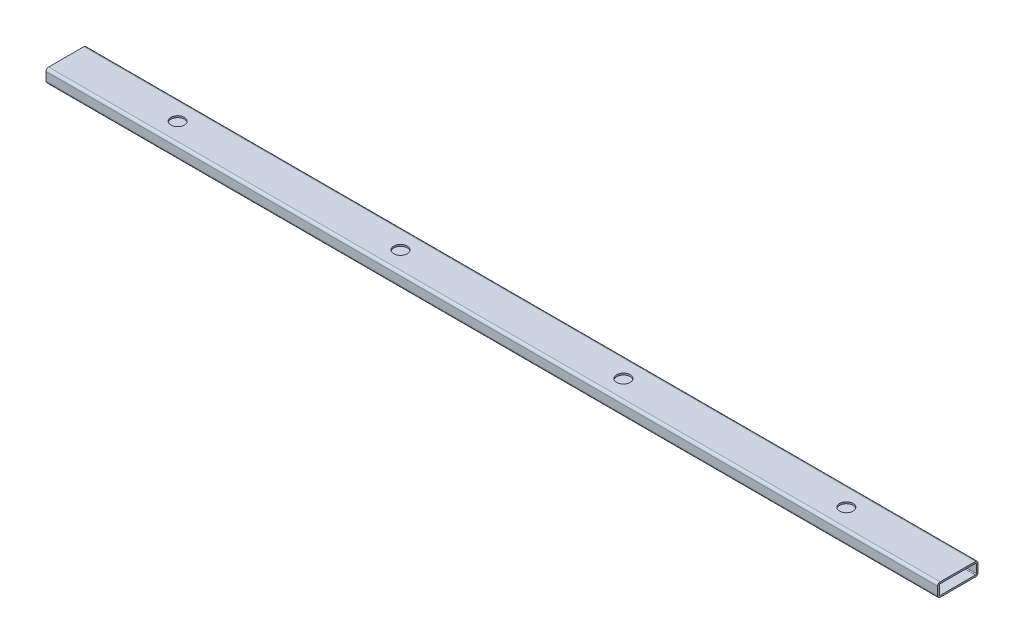
from build123d import *

# Parameters (mm, degrees)
BOSS_EXTRUDE1_DEPTH = 841.375
SKETCH2_R           = 12.7
CUT_EXTRUDE1_DEPTH  = 3.175
LPATTERN1_COUNT     = 4
LPATTERN1_PITCH     = 420.6875


with BuildPart() as part:
    # Sketch1 → Boss-Extrude1 (new body, symmetric)
    with BuildSketch(Plane(origin=(0, 0, 0), x_dir=(0, 0, -1), z_dir=(1, 0, 0))):
        with BuildLine():
            Line((33.3248, 25.4), (-33.3248, 25.4))
            ThreePointArc((-33.3248, 25.4), (-36.701376302, 24.001376302), (-38.1, 20.6248))
            Line((-38.1, 20.6248), (-38.1, 4.7752))
            ThreePointArc((-38.1, 4.7752), (-36.701376302, 1.398623698), (-33.3248, 0))
            Line((-33.3248, 0), (33.3248, 0))
            ThreePointArc((33.3248, 0), (36.701376302, 1.398623698), (38.1, 4.7752))
            Line((38.1, 4.7752), (38.1, 20.6248))
            ThreePointArc((38.1, 20.6248), (36.701376302, 24.001376302), (33.3248, 25.4))
        make_face()
        with BuildLine():
            Line((33.3248, 22.225), (-33.3248, 22.225))
            ThreePointArc((-33.3248, 22.225), (-34.456312271, 21.756312271), (-34.925, 20.6248))
            Line((-34.925, 20.6248), (-34.925, 4.7752))
            ThreePointArc((-34.925, 4.7752), (-34.456312271, 3.643687729), (-33.3248, 3.175))
            Line((-33.3248, 3.175), (33.3248, 3.175))
            ThreePointArc((33.3248, 3.175), (34.456312271, 3.643687729), (34.925, 4.7752))
            Line((34.925, 4.7752), (34.925, 20.6248))
            ThreePointArc((34.925, 20.6248), (34.456312271, 21.756312271), (33.3248, 22.225))
        make_face(mode=Mode.SUBTRACT)
    extrude(amount=BOSS_EXTRUDE1_DEPTH, both=True)

    # Sketch2 → Cut-Extrude1 (cut)
    with BuildSketch(Plane(origin=(0, 25.4, 0), x_dir=(1, 0, 0), z_dir=(0, 1, 0))):
        with Locations((-631.03125, 0)):
            Circle(SKETCH2_R)
    cut_extrude1 = extrude(amount=-CUT_EXTRUDE1_DEPTH, mode=Mode.SUBTRACT)

    # LPattern1: Cut-Extrude1 ×4
    with Locations(*[(i * LPATTERN1_PITCH, 0, 0) for i in range(1, LPATTERN1_COUNT)]):
        add(cut_extrude1, mode=Mode.SUBTRACT)


solid = part.part
